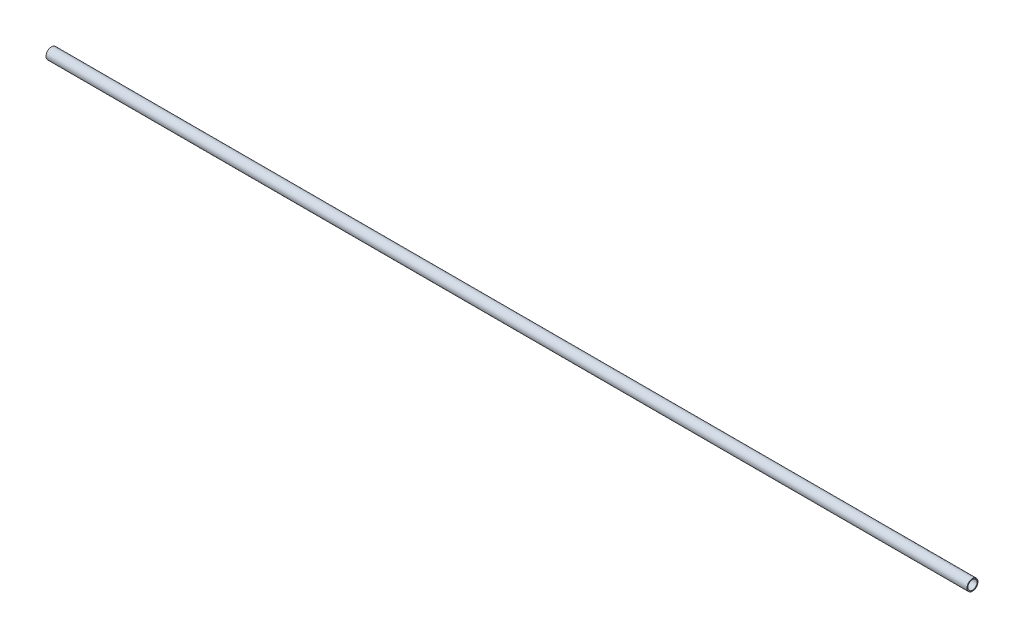
from build123d import *

# Parameters (mm, degrees)
SKETCH1_R          = 3
SKETCH1_R_2        = 2.5
SPAR_EXTRUDE_DEPTH = 500


with BuildPart() as part:
    # Sketch1 → spar_extrude (new body)
    with BuildSketch(Plane(origin=(0, 0, 0), x_dir=(0, 0, -1), z_dir=(1, 0, 0))):
        Circle(SKETCH1_R)
        Circle(SKETCH1_R_2, mode=Mode.SUBTRACT)
    extrude(amount=SPAR_EXTRUDE_DEPTH)


solid = part.part
